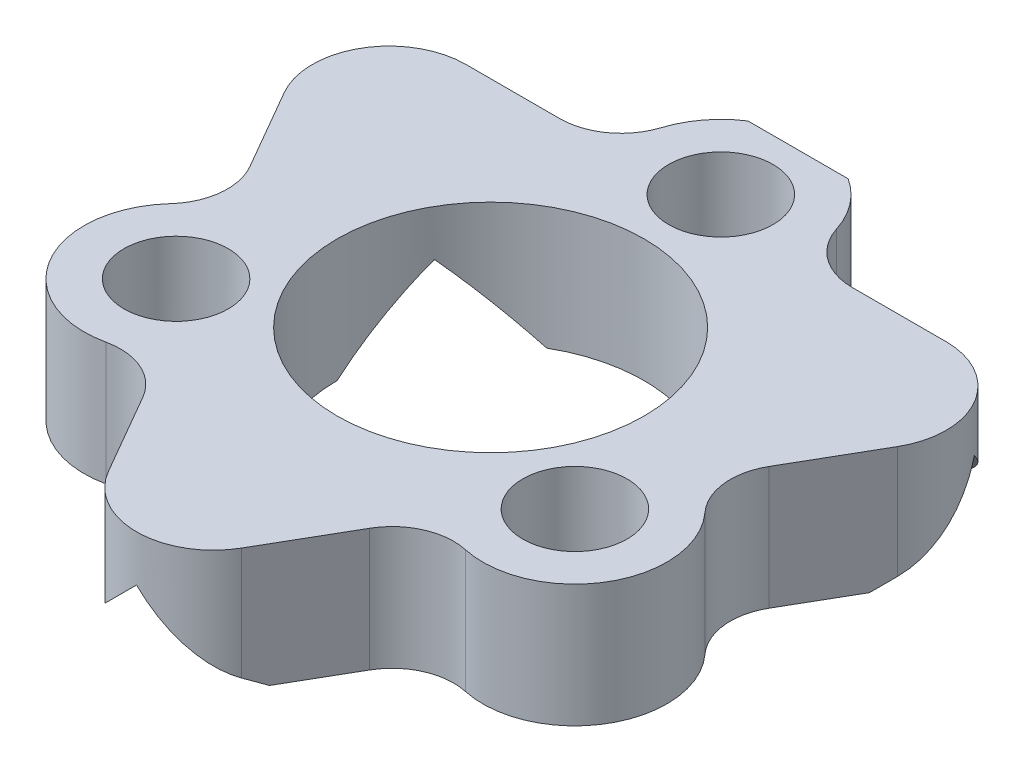
from build123d import *

# Parameters (mm, degrees)
SKETCH1_R                      = 5
EXTRUDE1_DEPTH                 = 4
CIRPATTERN2_COUNT              = 3
EXTRUDE4_START                 = 4.45086
EXTRUDE4_DEPTH                 = 7.205259
EXTRUDE5_START                 = 4.330127
EXTRUDE5_DEPTH                 = 7.205258
EXTRUDE6_START                 = 4.330127
EXTRUDE6_DEPTH                 = 7.205258
SKETCH11_W                     = 14.943105969
SKETCH11_H                     = 2.182700872
EXTRUDE7_DEPTH                 = 10
F_0_5_0_5_DIAMETER_HOLE1_D     = 0.5
F_0_5_0_5_DIAMETER_HOLE1_DEPTH = 0.25
F_0_5_0_5_DIAMETER_HOLE1_TIP   = 0.150215155
F_0_5_0_5_DIAMETER_HOLE2_D     = 0.5
F_0_5_0_5_DIAMETER_HOLE2_DEPTH = 0.25
F_0_5_0_5_DIAMETER_HOLE2_TIP   = 0.150215155
F_0_5_0_5_DIAMETER_HOLE3_D     = 0.5
F_0_5_0_5_DIAMETER_HOLE3_DEPTH = 0.25
F_0_5_0_5_DIAMETER_HOLE3_TIP   = 0.150215155


with BuildPart() as part:
    # Sketch1 → Extrude1 (new body)
    with BuildSketch(Plane(origin=(0, 0, 0), x_dir=(1, 0, 0), z_dir=(0, 1, 0))):
        with BuildLine():
            Line((-9.989936491, 3.146959138), (-8.459547932, 0.4962484))
            ThreePointArc((-8.459547932, 0.4962484), (-8.203164753, -0.718531203), (-8.713035455, -1.850544314))
            ThreePointArc((-8.713035455, -1.850544314), (-9.09326674, -5.370733384), (-5.854577936, -6.801537968))
            ThreePointArc((-5.854577936, -6.801537968), (-4.619290473, -6.925983542), (-3.695452068, -7.75540769))
            Line((-3.695452068, -7.75540769), (-2.165063509, -10.406118428))
            ThreePointArc((-2.165063509, -10.406118428), (0, -11.656118428), (2.165063509, -10.406118428))
            Line((2.165063509, -10.406118428), (3.695452068, -7.75540769))
            ThreePointArc((3.695452068, -7.75540769), (4.619290473, -6.925983542), (5.854577936, -6.801537968))
            ThreePointArc((5.854577936, -6.801537968), (9.09326674, -5.370733384), (8.713035455, -1.850544314))
            ThreePointArc((8.713035455, -1.850544314), (8.203164753, -0.718531203), (8.459547932, 0.4962484))
            Line((8.459547932, 0.4962484), (9.989936491, 3.146959138))
            ThreePointArc((9.989936491, 3.146959138), (9.989936491, 5.646959138), (7.824872981, 6.896959138))
            Line((7.824872981, 6.896959138), (4.764095865, 6.896959138))
            ThreePointArc((4.764095865, 6.896959138), (3.583874279, 7.282314592), (2.858457519, 8.289882129))
            ThreePointArc((2.858457519, 8.289882129), (0, 10.379266616), (-2.858457519, 8.289882129))
            ThreePointArc((-2.858457519, 8.289882129), (-3.583874279, 7.282314592), (-4.764095865, 6.896959138))
            Line((-4.764095865, 6.896959138), (-7.824872981, 6.896959138))
            ThreePointArc((-7.824872981, 6.896959138), (-9.989936491, 5.646959138), (-9.989936491, 3.146959138))
        make_face()
        with Locations((0, -0.120733384)):
            Circle(SKETCH1_R, mode=Mode.SUBTRACT)
    extrude(amount=EXTRUDE1_DEPTH)

    # Sketch6 → M3 Clearance Hole1 (revolve, cut)
    with BuildSketch(Plane(origin=(-6.495190528, 4, 3.870733384), x_dir=(0, 0, 1), z_dir=(1, 0, 0))):
        Polygon((0, 0), (0, 11.021463052), (1.7, 10), (1.7, 0), align=None)
    m3_clearance_hole1 = revolve(axis=Axis((-6.495190528, 10.35, 3.870733384), (0, -1, 0)), mode=Mode.SUBTRACT)

    # CirPattern2: M3 Clearance Hole1 ×3 about axis
    cirpattern2_axis = Axis((0, 0, 0.120733384), (0, 1, 0))
    for i in range(1, CIRPATTERN2_COUNT):
        add(m3_clearance_hole1.rotate(cirpattern2_axis, i * 360 / CIRPATTERN2_COUNT), mode=Mode.SUBTRACT)

    # GrooveSketch → Extrude4 (cut)
    with BuildSketch(Plane.XY.offset(EXTRUDE4_START)):
        Polygon((28.569876563, -26.069876563), (2.5, 0), (0, 2.5), (-2.5, 0), (-28.569876563, -26.069876563), (-28.569876563, -99.806622573), (28.569876563, -99.806622573), align=None)
    extrude(amount=EXTRUDE4_DEPTH, mode=Mode.SUBTRACT)

    # Sketch9 → Extrude5 (cut)
    with BuildSketch(Plane(origin=(0.052279089, 0, 0.030183346), x_dir=(-0.5, 0, 0.866025404), z_dir=(-0.866025404, 0, -0.5)).offset(EXTRUDE5_START)):
        Polygon((35.272745822, -32.668187644), (2.604558178, 0), (0.104558178, 2.5), (-2.395441822, 0), (-35.063629467, -32.668187644), (-35.063629467, -125.067775694), (35.272745822, -125.067775694), align=None)
    extrude(amount=EXTRUDE5_DEPTH, mode=Mode.SUBTRACT)

    # Sketch10 → Extrude6 (cut)
    with BuildSketch(Plane(origin=(-0.052279089, 0, 0.030183346), x_dir=(-0.5, 0, -0.866025404), z_dir=(0.866025404, 0, -0.5)).offset(EXTRUDE6_START)):
        Polygon((35.063629467, -32.668187644), (2.395441822, 0), (-0.104558178, 2.5), (-2.604558178, 0), (-35.272745822, -32.668187644), (-35.272745822, -125.067775694), (35.063629467, -125.067775694), align=None)
    extrude(amount=EXTRUDE6_DEPTH, mode=Mode.SUBTRACT)

    # Sketch11 → Extrude7 (cut)
    with BuildSketch(Plane(origin=(0, 4, 0), x_dir=(-1, 0, 0), z_dir=(0, 1, 0))):
        with Locations((-0.195883412, -10.988309574)):
            Rectangle(SKETCH11_W, SKETCH11_H)
    extrude(amount=-EXTRUDE7_DEPTH, mode=Mode.SUBTRACT)

    # Ø0.5 (0.5) Diameter Hole1
    with Locations(Plane(origin=(0, 2.5, -9.896959138), x_dir=(-1, 0, 0), z_dir=(0, 0, -1))):
        with Locations((0, 0)):
            Hole(F_0_5_0_5_DIAMETER_HOLE1_D / 2, depth=F_0_5_0_5_DIAMETER_HOLE1_DEPTH)
            with Locations((0, 0, -(F_0_5_0_5_DIAMETER_HOLE1_DEPTH + F_0_5_0_5_DIAMETER_HOLE1_TIP / 2))):  # 118° drill point
                Cone(0, F_0_5_0_5_DIAMETER_HOLE1_D / 2, F_0_5_0_5_DIAMETER_HOLE1_TIP, mode=Mode.SUBTRACT)

    # Ø0.5 (0.5) Diameter Hole2
    with Locations(Plane(origin=(6.5, 2.5, -6.896959138), x_dir=(-1, 0, 0), z_dir=(0, 0, -1))):
        with Locations((0, 0)):
            Hole(F_0_5_0_5_DIAMETER_HOLE2_D / 2, depth=F_0_5_0_5_DIAMETER_HOLE2_DEPTH)
            with Locations((0, 0, -(F_0_5_0_5_DIAMETER_HOLE2_DEPTH + F_0_5_0_5_DIAMETER_HOLE2_TIP / 2))):  # 118° drill point
                Cone(0, F_0_5_0_5_DIAMETER_HOLE2_D / 2, F_0_5_0_5_DIAMETER_HOLE2_TIP, mode=Mode.SUBTRACT)

    # Ø0.5 (0.5) Diameter Hole3
    with Locations(Plane(origin=(-6.5, 2.5, -6.896959138), x_dir=(-1, 0, 0), z_dir=(0, 0, -1))):
        with Locations((0, 0)):
            Hole(F_0_5_0_5_DIAMETER_HOLE3_D / 2, depth=F_0_5_0_5_DIAMETER_HOLE3_DEPTH)
            with Locations((0, 0, -(F_0_5_0_5_DIAMETER_HOLE3_DEPTH + F_0_5_0_5_DIAMETER_HOLE3_TIP / 2))):  # 118° drill point
                Cone(0, F_0_5_0_5_DIAMETER_HOLE3_D / 2, F_0_5_0_5_DIAMETER_HOLE3_TIP, mode=Mode.SUBTRACT)


solid = part.part
